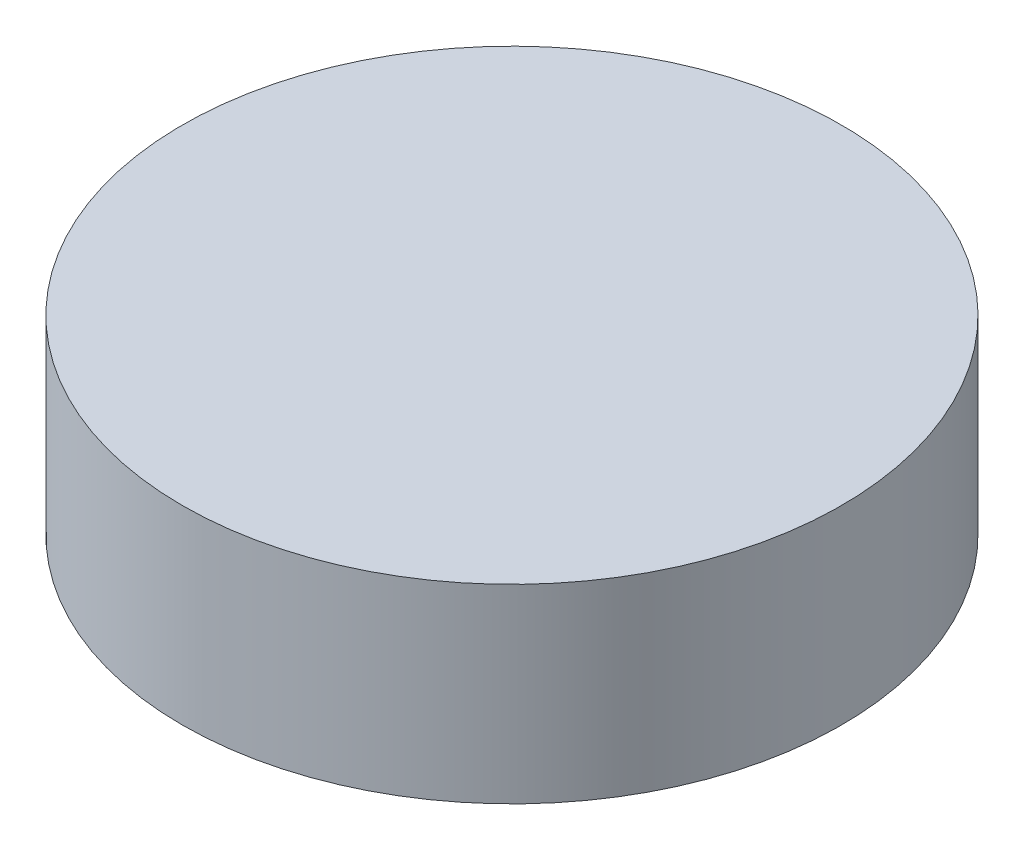
from build123d import *

# Parameters (mm, degrees)
SKETCH1_R           = 13
BOSS_EXTRUDE1_DEPTH = 7.5


with BuildPart() as part:
    # Sketch1 → Boss-Extrude1 (new body)
    with BuildSketch(Plane(origin=(0, 0, 0), x_dir=(1, 0, 0), z_dir=(0, 1, 0))):
        Circle(SKETCH1_R)
    extrude(amount=BOSS_EXTRUDE1_DEPTH)


solid = part.part
